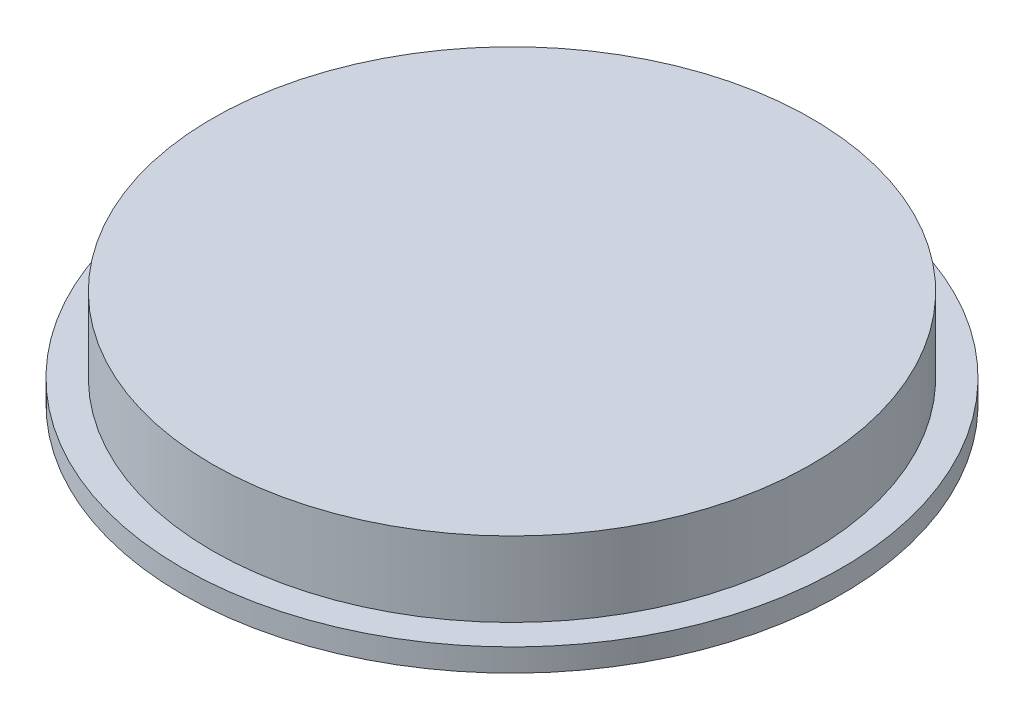
from build123d import *


with BuildPart() as part:
    # Sketch1 → Revolve1 (revolve)
    with BuildSketch(Plane.XY):
        Polygon((0, 13.516872382), (50.8, 13.516872382), (50.8, 0.816872382), (55.88, 0.816872382), (55.88, -3.036746306), (47.15983465, -3.036746306), (38.1, 1.670674941), (0, 1.670674941), align=None)
    revolve(axis=Axis((0, 45.293153527, 0), (0, -1, 0)))


solid = part.part
